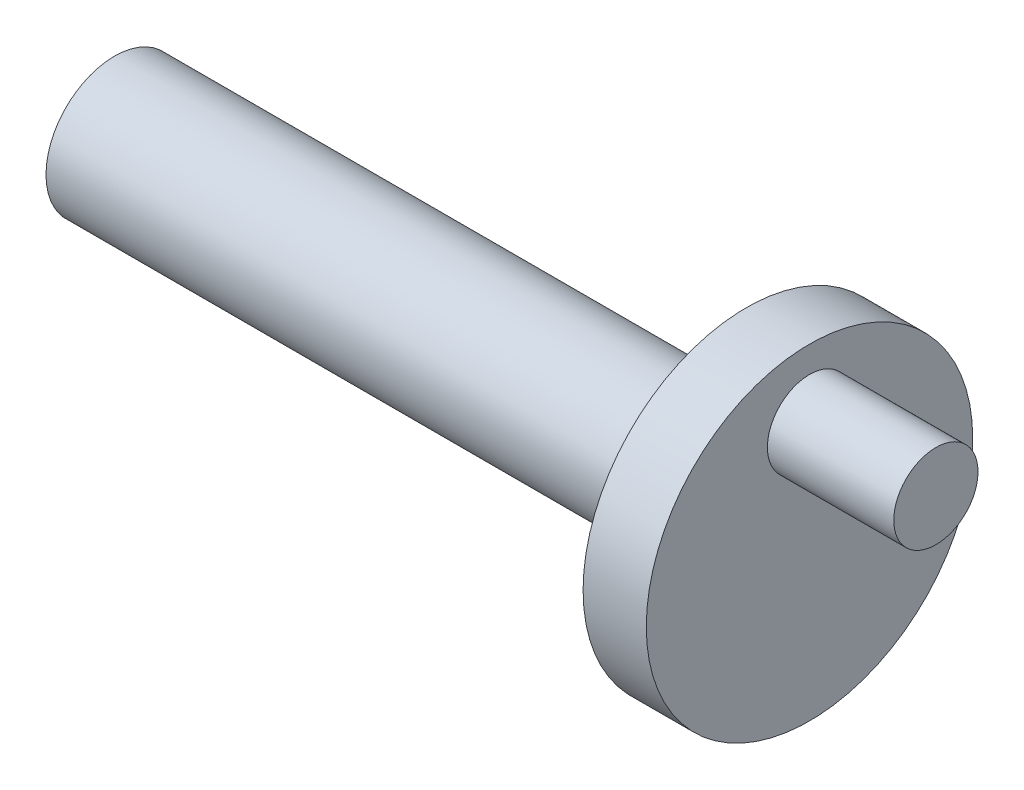
from build123d import *

# Parameters (mm, degrees)
SKETCH1_R           = 15.5
BOSS_EXTRUDE1_DEPTH = 6
SKETCH2_R           = 6.5
BOSS_EXTRUDE2_DEPTH = 60
FILLET1_R           = 1
SKETCH3_R           = 4
BOSS_EXTRUDE3_DEPTH = 12


with BuildPart() as part:
    # Sketch1 → Boss-Extrude1 (new body)
    with BuildSketch(Plane(origin=(0, 0, 0), x_dir=(0, 0, -1), z_dir=(1, 0, 0))):
        Circle(SKETCH1_R)
    extrude(amount=BOSS_EXTRUDE1_DEPTH)

    # Sketch2 → Boss-Extrude2 (add)
    with BuildSketch(Plane.ZY):
        with Locations((0, -0.321626653)):
            Circle(SKETCH2_R)
    extrude(amount=BOSS_EXTRUDE2_DEPTH)

    # Fillet1
    fillet1_edges = [part.edges().sort_by_distance(p)[0] for p in [
        (0, -0.321626653, -6.5),
    ]]
    fillet(fillet1_edges, radius=FILLET1_R)

    # Sketch3 → Boss-Extrude3 (add)
    with BuildSketch(Plane(origin=(6, 0, 0), x_dir=(0, 0, -1), z_dir=(1, 0, 0))):
        with Locations((0, 9)):
            Circle(SKETCH3_R)
    extrude(amount=BOSS_EXTRUDE3_DEPTH)


solid = part.part
